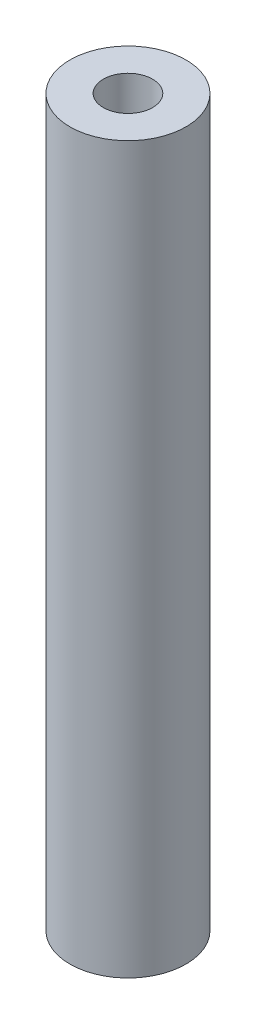
from build123d import *

# Parameters (mm, degrees)
SKETCH1_R           = 40
SKETCH1_R_2         = 17
BOSS_EXTRUDE1_DEPTH = 500


with BuildPart() as part:
    # Sketch1 → Boss-Extrude1 (new body)
    with BuildSketch(Plane(origin=(0, 0, 0), x_dir=(1, 0, 0), z_dir=(0, 1, 0))):
        Circle(SKETCH1_R)
        Circle(SKETCH1_R_2, mode=Mode.SUBTRACT)
    extrude(amount=BOSS_EXTRUDE1_DEPTH)


solid = part.part
